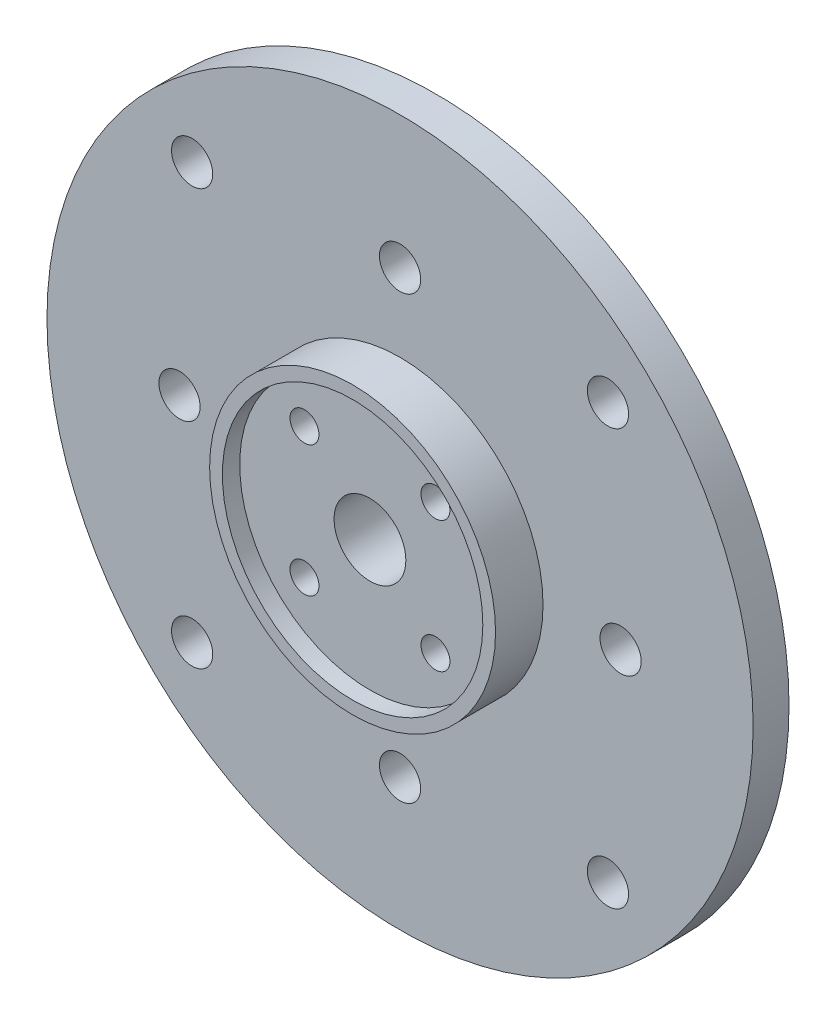
from build123d import *

# Parameters (mm, degrees)
SKETCH1_R           = 30.5
SKETCH1_R_2         = 1.78
BOSS_EXTRUDE1_DEPTH = 3.1
SKETCH2_R           = 12.35
BOSS_EXTRUDE2_DEPTH = 4.1
SKETCH3_R           = 11.25
CUT_EXTRUDE1_DEPTH  = 1.5
SKETCH4_R           = 1.25
SKETCH4_R_2         = 3.1
CUT_EXTRUDE2_DEPTH  = 6.7


with BuildPart() as part:
    # Sketch1 → Boss-Extrude1 (new body)
    with BuildSketch(Plane.XY):
        Circle(SKETCH1_R)
        with Locations((0, 19.05)):
            Circle(SKETCH1_R_2, mode=Mode.SUBTRACT)
        with Locations((19.05, 0)):
            Circle(SKETCH1_R_2, mode=Mode.SUBTRACT)
        with Locations((0, -19.05)):
            Circle(SKETCH1_R_2, mode=Mode.SUBTRACT)
        with Locations((-19.05, 0)):
            Circle(SKETCH1_R_2, mode=Mode.SUBTRACT)
        with Locations((17.960512242, 17.960512242)):
            Circle(SKETCH1_R_2, mode=Mode.SUBTRACT)
        with Locations((17.960512242, -17.960512242)):
            Circle(SKETCH1_R_2, mode=Mode.SUBTRACT)
        with Locations((-17.960512242, -17.960512242)):
            Circle(SKETCH1_R_2, mode=Mode.SUBTRACT)
        with Locations((-17.960512242, 17.960512242)):
            Circle(SKETCH1_R_2, mode=Mode.SUBTRACT)
    extrude(amount=BOSS_EXTRUDE1_DEPTH)

    # Sketch2 → Boss-Extrude2 (add)
    with BuildSketch(Plane.XY.offset(3.1)):
        Circle(SKETCH2_R)
    extrude(amount=BOSS_EXTRUDE2_DEPTH)

    # Sketch3 → Cut-Extrude1 (cut)
    with BuildSketch(Plane.XY.offset(7.2)):
        Circle(SKETCH3_R)
    extrude(amount=-CUT_EXTRUDE1_DEPTH, mode=Mode.SUBTRACT)

    # Sketch4 → Cut-Extrude2 (cut, through all)
    with BuildSketch(Plane.XY.offset(5.7)):
        with Locations((5.656854249, 5.656854249)):
            Circle(SKETCH4_R)
        with Locations((5.656854249, -5.656854249)):
            Circle(SKETCH4_R)
        with Locations((-5.656854249, -5.656854249)):
            Circle(SKETCH4_R)
        with Locations((-5.656854249, 5.656854249)):
            Circle(SKETCH4_R)
        Circle(SKETCH4_R_2)
    extrude(amount=-CUT_EXTRUDE2_DEPTH, mode=Mode.SUBTRACT)


solid = part.part
